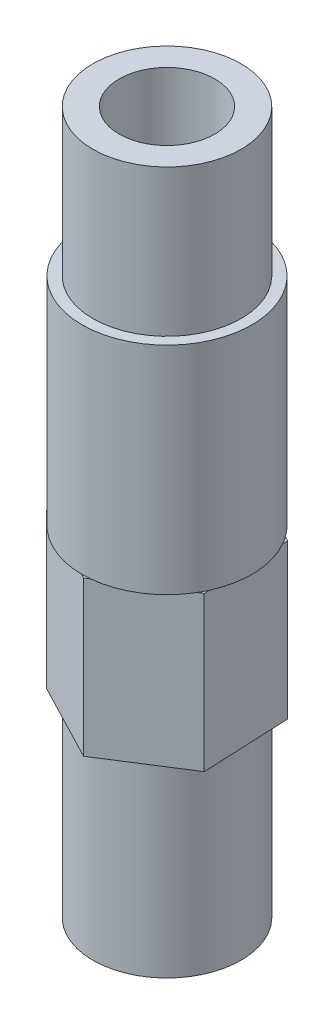
from build123d import *

# Parameters (mm, degrees)
SKETCH_2_R          = 4.8
EXTRUDE_1_DEPTH     = 12
EXTRUDE_2_DEPTH     = 10
SKETCH_4_R          = 5.5
EXTRUDE_3_DEPTH     = 14
SKETCH_5_R          = 4.8
EXTRUDE_4_DEPTH     = 9.5
SKETCH_6_R          = 3.1
CUT_EXTRUDE_1_DEPTH = 46.5


with BuildPart() as part:
    # Эскиз2 → Бобышка-Вытянуть1 (new body)
    with BuildSketch(Plane(origin=(0, 0, 0), x_dir=(1, 0, 0), z_dir=(0, 1, 0))):
        Circle(SKETCH_2_R)
    extrude(amount=EXTRUDE_1_DEPTH)

    # Эскиз3 → Бобышка-Вытянуть2 (add)
    with BuildSketch(Plane(origin=(0, 12, 0), x_dir=(1, 0, 0), z_dir=(0, 1, 0))):
        Polygon((5.0208225, -2.608577151), (4.769505331, 3.043871258), (-0.251317169, 5.652448409), (-5.0208225, 2.608577151), (-4.769505331, -3.043871258), (0.251317169, -5.652448409), align=None)
    extrude(amount=EXTRUDE_2_DEPTH)

    # Эскиз4 → Бобышка-Вытянуть3 (add)
    with BuildSketch(Plane(origin=(0, 22, 0), x_dir=(1, 0, 0), z_dir=(0, 1, 0))):
        Circle(SKETCH_4_R)
    extrude(amount=EXTRUDE_3_DEPTH)

    # Эскиз5 → Бобышка-Вытянуть4 (add)
    with BuildSketch(Plane(origin=(0, 36, 0), x_dir=(1, 0, 0), z_dir=(0, 1, 0))):
        Circle(SKETCH_5_R)
    extrude(amount=EXTRUDE_4_DEPTH)

    # Эскиз6 → Вырез-Вытянуть1 (cut, through all)
    with BuildSketch(Plane(origin=(0, 45.5, 0), x_dir=(1, 0, 0), z_dir=(0, 1, 0))):
        Circle(SKETCH_6_R)
    extrude(amount=-CUT_EXTRUDE_1_DEPTH, mode=Mode.SUBTRACT)


solid = part.part
